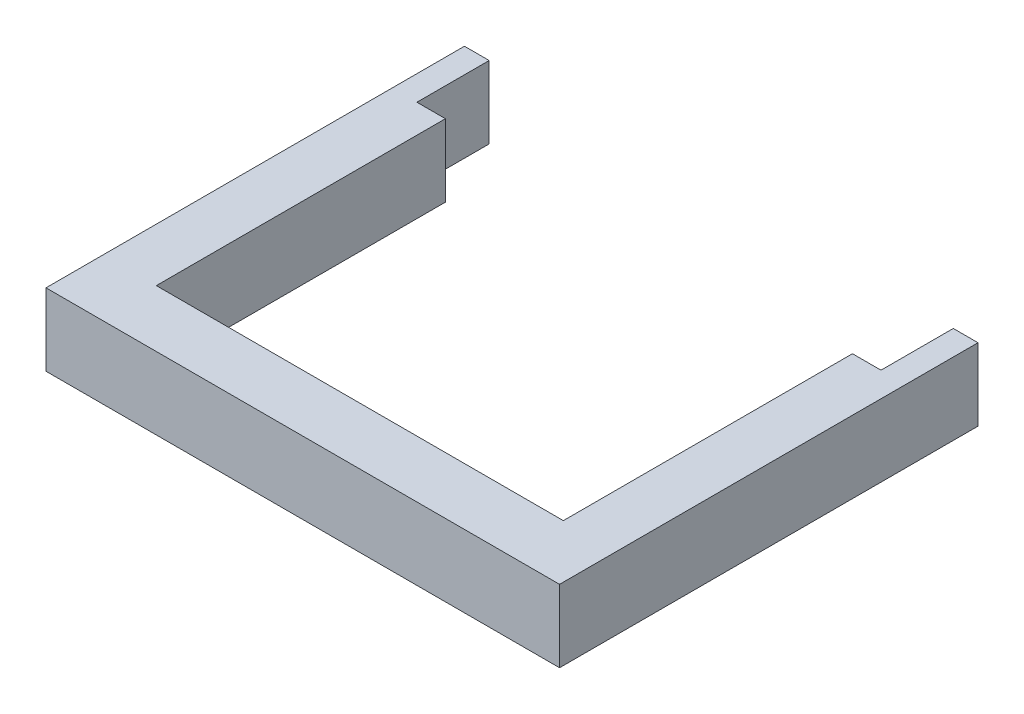
from build123d import *

# Parameters (mm, degrees)
BOSS_EXTRUDE1_DEPTH = 3.8


with BuildPart() as part:
    # Sketch1 → Boss-Extrude1 (new body)
    with BuildSketch(Plane(origin=(0, 0, 0), x_dir=(1, 0, 0), z_dir=(0, 1, 0))):
        Polygon((-13.5, 0), (13.5, 0), (13.5, 22), (12.2, 22), (12.2, 18.2), (10.7, 18.2), (10.7, 3), (-10.7, 3), (-10.7, 18.2), (-12.2, 18.2), (-12.2, 22), (-13.5, 22), align=None)
    extrude(amount=BOSS_EXTRUDE1_DEPTH)


solid = part.part
